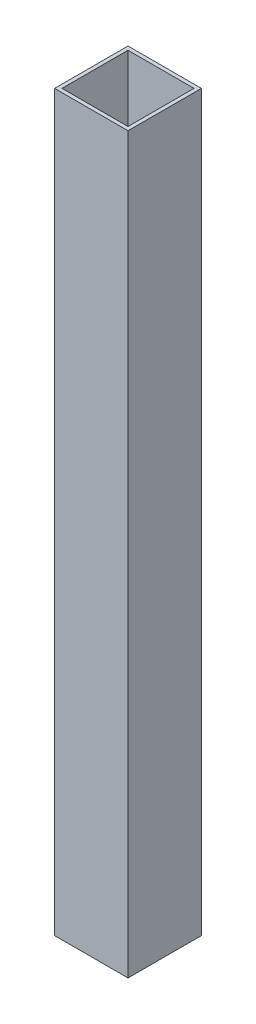
from build123d import *

# Parameters (mm, degrees)
SKETCH1_W           = 20
SKETCH1_H           = 20
SKETCH1_W_2         = 18
SKETCH1_H_2         = 18
BOSS_EXTRUDE1_DEPTH = 200


with BuildPart() as part:
    # Sketch1 → Boss-Extrude1 (new body)
    with BuildSketch(Plane(origin=(0, 0, 0), x_dir=(1, 0, 0), z_dir=(0, 1, 0))):
        Rectangle(SKETCH1_W, SKETCH1_H)
        Rectangle(SKETCH1_W_2, SKETCH1_H_2, mode=Mode.SUBTRACT)
    extrude(amount=BOSS_EXTRUDE1_DEPTH)


solid = part.part
